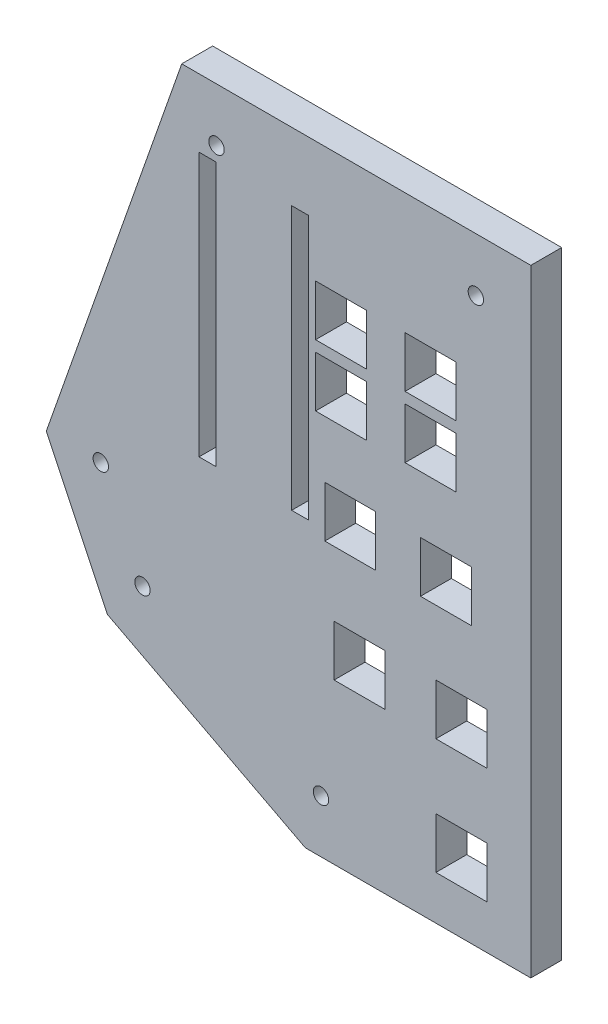
from build123d import *

# Parameters (mm, degrees)
BOSS_EXTRUDE1_DEPTH = 5.08
SKETCH5_W           = 8.382
SKETCH5_H           = 8.382
SKETCH5_W_2         = 2.794
SKETCH5_H_2         = 43.434
CUT_EXTRUDE1_DEPTH  = 6.08
SKETCH7_R           = 1.27
CUT_EXTRUDE3_DEPTH  = 6.08


with BuildPart() as part:
    # Sketch1 → Boss-Extrude1 (new body)
    with BuildSketch(Plane.XY):
        Polygon((-4.120444444, 6.35), (53.34, 6.35), (53.34, -95.25), (16.22499019, -95.25), (-16.356614113, -78.274710363), (-26.416, -57.15), align=None)
    extrude(amount=BOSS_EXTRUDE1_DEPTH)

    # Sketch5 → Cut-Extrude1 (cut, through all)
    with BuildSketch(Plane(origin=(0, 0, 0), x_dir=(-1, 0, 0), z_dir=(0, 0, -1))):
        with Locations((-36.83, -17.78)):
            Rectangle(SKETCH5_W, SKETCH5_H)
        with Locations((-39.37, -45.72)):
            Rectangle(SKETCH5_W, SKETCH5_H)
        with Locations((-36.83, -27.94)):
            Rectangle(SKETCH5_W, SKETCH5_H)
        with Locations((-41.91, -64.77)):
            Rectangle(SKETCH5_W, SKETCH5_H)
        with Locations((-41.91, -83.82)):
            Rectangle(SKETCH5_W, SKETCH5_H)
        with Locations((-22.098, -17.78)):
            Rectangle(SKETCH5_W, SKETCH5_H)
        with Locations((-22.098, -27.94)):
            Rectangle(SKETCH5_W, SKETCH5_H)
        with Locations((-23.622, -45.72)):
            Rectangle(SKETCH5_W, SKETCH5_H)
        with Locations((-25.146, -64.77)):
            Rectangle(SKETCH5_W, SKETCH5_H)
        with Locations((-15.367, -26.543)):
            Rectangle(SKETCH5_W_2, SKETCH5_H_2)
        with Locations((-0.127, -26.543)):
            Rectangle(SKETCH5_W_2, SKETCH5_H_2)
    extrude(amount=-CUT_EXTRUDE1_DEPTH, mode=Mode.SUBTRACT)

    # Sketch7 → Cut-Extrude3 (cut, through all)
    with BuildSketch(Plane.XY.offset(5.08)):
        with Locations((44.2976, -2.4892)):
            Circle(SKETCH7_R)
        with Locations((1.6002, -2.4384)):
            Circle(SKETCH7_R)
        with Locations((-17.4498, -57.15)):
            Circle(SKETCH7_R)
        with Locations((-10.5918, -71.3486)):
            Circle(SKETCH7_R)
        with Locations((18.796, -86.5378)):
            Circle(SKETCH7_R)
    extrude(amount=-CUT_EXTRUDE3_DEPTH, mode=Mode.SUBTRACT)


solid = part.part
